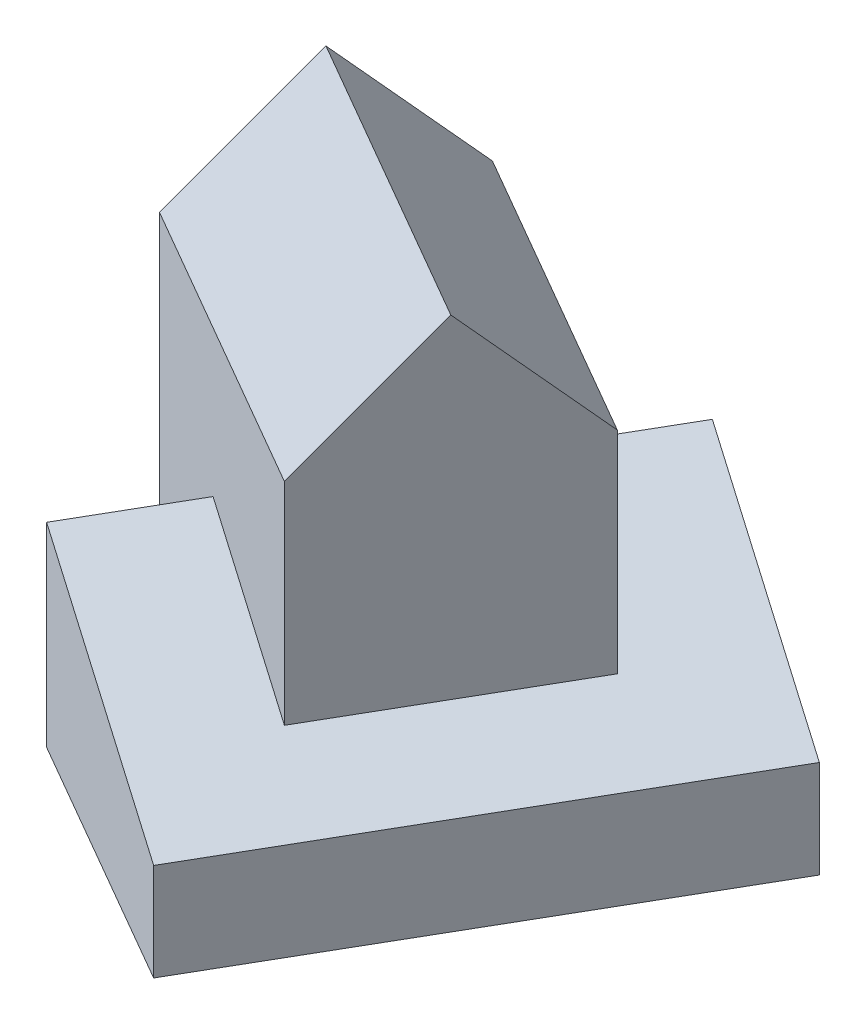
from build123d import *

# Parameters (mm, degrees)
EXTRUDE1_DEPTH     = 40
CUT_EXTRUDE1_DEPTH = 126.980762114
EXTRUDE2_DEPTH     = 70
EXTRUDE3_DEPTH     = 70


with BuildPart() as part:
    # Sketch1 → Extrude1 (new body)
    with BuildSketch(Plane(origin=(0, 0, 0), x_dir=(1, 0, 0), z_dir=(0, 1, 0))):
        Polygon((0, 0), (50, 86.602540378), (-1.961524227, 116.602540378), (-51.961524227, 30), align=None)
    extrude(amount=EXTRUDE1_DEPTH)

    # Sketch2 → Cut-Extrude1 (cut, through all)
    with BuildSketch(Plane(origin=(0, 0, 0), x_dir=(0.866025404, 0, 0.5), z_dir=(-0.5, 0, 0.866025404))):
        Polygon((0, 20), (-60, 40), (0, 40), align=None)
    extrude(amount=-CUT_EXTRUDE1_DEPTH, mode=Mode.SUBTRACT)

    # Sketch3 → Extrude2 (add)
    with BuildSketch(Plane(origin=(0, 0, 0), x_dir=(1, 0, 0), z_dir=(0, 1, 0))):
        Polygon((-65.442286341, 66.650635095), (-40.442286341, 109.951905284), (20.179491924, 74.951905284), (-4.820508076, 31.650635095), align=None)
    extrude(amount=EXTRUDE2_DEPTH)

    # Sketch4 → Extrude3 (add)
    with BuildSketch(Plane(origin=(-17.320508076, 0, -10), x_dir=(0.5, 0, -0.866025404), z_dir=(0.866025404, 0, 0.5))):
        Polygon((25, 70), (75, 70), (50, 95), align=None)
    extrude(amount=-EXTRUDE3_DEPTH)


solid = part.part
